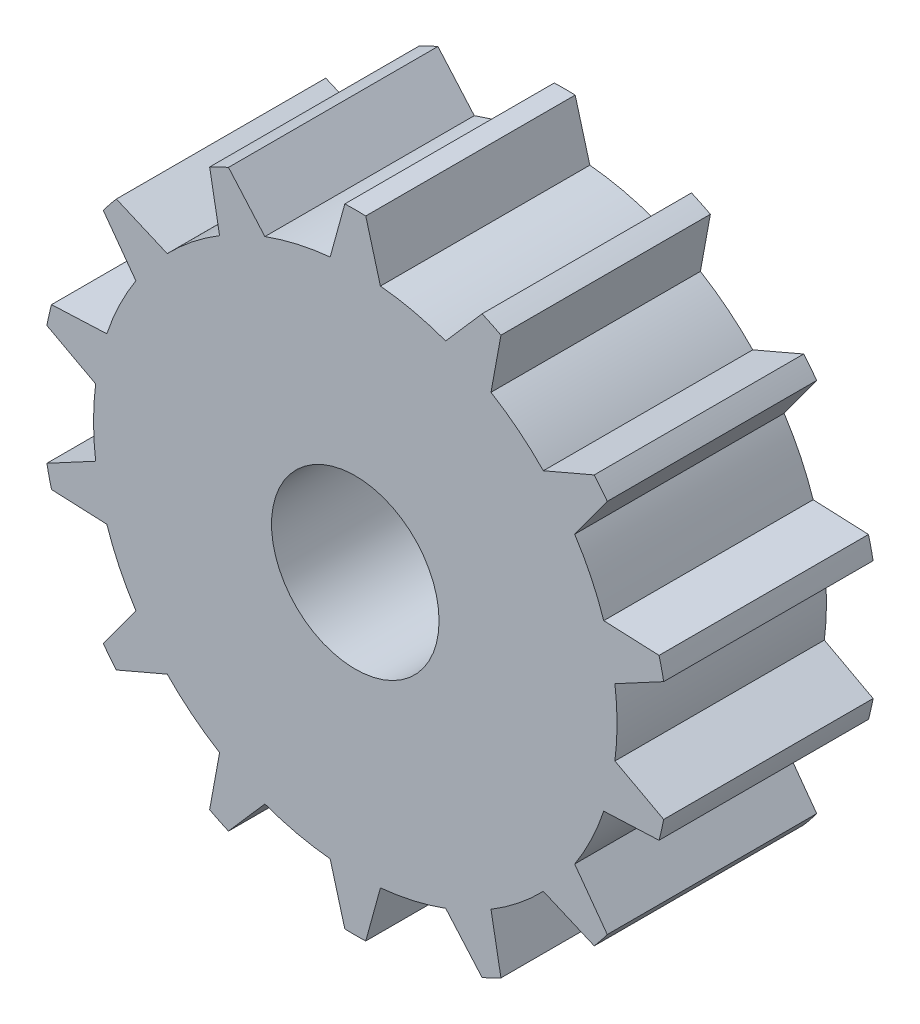
from build123d import *

# Parameters (mm, degrees)
ESQUISSE2_R        = 4
BOSS_EXTRU_1_DEPTH = 10


with BuildPart() as part:
    # Esquisse2 → Boss.-Extru.1 (new body)
    with BuildSketch(Plane.XY):
        with BuildLine():
            ThreePointArc((-19.500069449, 14.991666667), (-20, 15), (-20.499930551, 14.991666667))
            Line((-20.499930551, 14.991666667), (-21.2, 12.442266675))
            ThreePointArc((-21.2, 12.442266675), (-22.781511674, 12.186598902), (-24.317334546, 11.730755407))
            Line((-24.317334546, 11.730755407), (-26.054218527, 13.723936681))
            ThreePointArc((-26.054218527, 13.723936681), (-26.508256087, 13.514533019), (-26.955062251, 13.290113208))
            Line((-26.955062251, 13.290113208), (-26.479659829, 10.689434433))
            ThreePointArc((-26.479659829, 10.689434433), (-27.793622523, 9.772893531), (-28.979568037, 8.695824163))
            Line((-28.979568037, 8.695824163), (-31.409255375, 9.738012723))
            ThreePointArc((-31.409255375, 9.738012723), (-31.727472237, 9.352347028), (-32.032658575, 8.956289836))
            Line((-32.032658575, 8.956289836), (-30.475943562, 6.819428605))
            ThreePointArc((-30.475943562, 6.819428605), (-31.262110849, 5.423546739), (-31.863287951, 3.938578296))
            Line((-31.863287951, 3.938578296), (-34.50454927, 3.823355916))
            ThreePointArc((-34.50454927, 3.823355916), (-34.623918683, 3.337814009), (-34.727039297, 2.84856342))
            Line((-34.727039297, 2.84856342), (-32.397338193, 1.598751306))
            ThreePointArc((-32.397338193, 1.598751306), (-32.5, 0), (-32.397338193, -1.598751306))
            Line((-32.397338193, -1.598751306), (-34.727039297, -2.84856342))
            ThreePointArc((-34.727039297, -2.84856342), (-34.623918683, -3.337814009), (-34.50454927, -3.823355916))
            Line((-34.50454927, -3.823355916), (-31.863287951, -3.938578296))
            ThreePointArc((-31.863287951, -3.938578296), (-31.262110849, -5.423546739), (-30.475943562, -6.819428605))
            Line((-30.475943562, -6.819428605), (-32.032658575, -8.956289836))
            ThreePointArc((-32.032658575, -8.956289836), (-31.727472237, -9.352347028), (-31.409255375, -9.738012723))
            Line((-31.409255375, -9.738012723), (-28.979568037, -8.695824163))
            ThreePointArc((-28.979568037, -8.695824163), (-27.793622523, -9.772893531), (-26.479659829, -10.689434433))
            Line((-26.479659829, -10.689434433), (-26.955062251, -13.290113208))
            ThreePointArc((-26.955062251, -13.290113208), (-26.508256087, -13.514533019), (-26.054218527, -13.723936681))
            Line((-26.054218527, -13.723936681), (-24.317334546, -11.730755407))
            ThreePointArc((-24.317334546, -11.730755407), (-22.781511674, -12.186598902), (-21.2, -12.442266675))
            Line((-21.2, -12.442266675), (-20.499930551, -14.991666667))
            ThreePointArc((-20.499930551, -14.991666667), (-20, -15), (-19.500069449, -14.991666667))
            Line((-19.500069449, -14.991666667), (-18.8, -12.442266675))
            ThreePointArc((-18.8, -12.442266675), (-17.218488326, -12.186598902), (-15.682665454, -11.730755407))
            Line((-15.682665454, -11.730755407), (-13.945781473, -13.723936681))
            ThreePointArc((-13.945781473, -13.723936681), (-13.491743913, -13.514533019), (-13.044937749, -13.290113208))
            Line((-13.044937749, -13.290113208), (-13.520340171, -10.689434433))
            ThreePointArc((-13.520340171, -10.689434433), (-12.206377477, -9.772893531), (-11.020431963, -8.695824163))
            Line((-11.020431963, -8.695824163), (-8.590744625, -9.738012723))
            ThreePointArc((-8.590744625, -9.738012723), (-8.272527763, -9.352347028), (-7.967341425, -8.956289836))
            Line((-7.967341425, -8.956289836), (-9.524056438, -6.819428605))
            ThreePointArc((-9.524056438, -6.819428605), (-8.737889151, -5.423546739), (-8.136712049, -3.938578296))
            Line((-8.136712049, -3.938578296), (-5.49545073, -3.823355916))
            ThreePointArc((-5.49545073, -3.823355916), (-5.376081317, -3.337814009), (-5.272960703, -2.84856342))
            Line((-5.272960703, -2.84856342), (-7.602661807, -1.598751306))
            ThreePointArc((-7.602661807, -1.598751306), (-7.5, 0), (-7.602661807, 1.598751306))
            Line((-7.602661807, 1.598751306), (-5.272960703, 2.84856342))
            ThreePointArc((-5.272960703, 2.84856342), (-5.376081317, 3.337814009), (-5.49545073, 3.823355916))
            Line((-5.49545073, 3.823355916), (-8.136712049, 3.938578296))
            ThreePointArc((-8.136712049, 3.938578296), (-8.737889151, 5.423546739), (-9.524056438, 6.819428605))
            Line((-9.524056438, 6.819428605), (-7.967341425, 8.956289836))
            ThreePointArc((-7.967341425, 8.956289836), (-8.272527763, 9.352347028), (-8.590744625, 9.738012723))
            Line((-8.590744625, 9.738012723), (-11.020431963, 8.695824163))
            ThreePointArc((-11.020431963, 8.695824163), (-12.206377477, 9.772893531), (-13.520340171, 10.689434433))
            Line((-13.520340171, 10.689434433), (-13.044937749, 13.290113208))
            ThreePointArc((-13.044937749, 13.290113208), (-13.491743913, 13.514533019), (-13.945781473, 13.723936681))
            Line((-13.945781473, 13.723936681), (-15.682665454, 11.730755407))
            ThreePointArc((-15.682665454, 11.730755407), (-17.218488326, 12.186598902), (-18.8, 12.442266675))
            Line((-18.8, 12.442266675), (-19.500069449, 14.991666667))
        make_face()
        with Locations((-20, 0)):
            Circle(ESQUISSE2_R, mode=Mode.SUBTRACT)
    extrude(amount=BOSS_EXTRU_1_DEPTH)


solid = part.part
